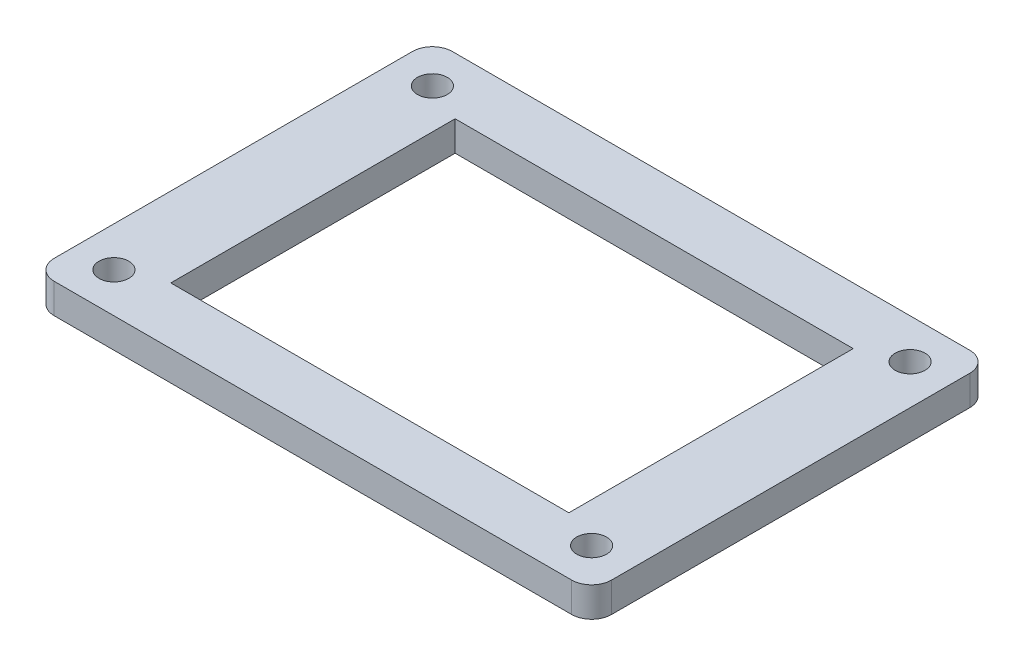
from build123d import *

# Parameters (mm, degrees)
SKETCH2_W           = 56
SKETCH2_H           = 40
SKETCH2_W_2         = 40
SKETCH2_H_2         = 28.571428572
BOSS_EXTRUDE2_DEPTH = 3
SKETCH3_R           = 1.5
CUT_EXTRUDE1_DEPTH  = 4
FILLET1_R           = 2


with BuildPart() as part:
    # Sketch2 → Boss-Extrude2 (new body)
    with BuildSketch(Plane(origin=(0, 0, 0), x_dir=(1, 0, 0), z_dir=(0, 1, 0))):
        Rectangle(SKETCH2_W, SKETCH2_H)
        Rectangle(SKETCH2_W_2, SKETCH2_H_2, mode=Mode.SUBTRACT)
    extrude(amount=BOSS_EXTRUDE2_DEPTH)

    # Sketch3 → Cut-Extrude1 (cut, through all)
    with BuildSketch(Plane(origin=(0, 0, 0), x_dir=(-1, 0, 0), z_dir=(0, -1, 0))):
        with Locations((24, -16)):
            Circle(SKETCH3_R)
        with Locations((-24, 16)):
            Circle(SKETCH3_R)
        with Locations((-24, -16)):
            Circle(SKETCH3_R)
        with Locations((24, 16)):
            Circle(SKETCH3_R)
    extrude(amount=-CUT_EXTRUDE1_DEPTH, mode=Mode.SUBTRACT)

    # Fillet1
    fillet1_edges = [part.edges().sort_by_distance(p)[0] for p in [
        (28, 1.5, 20),
        (-28, 1.5, 20),
        (-28, 1.5, -20),
        (28, 1.5, -20),
    ]]
    fillet(fillet1_edges, radius=FILLET1_R)


solid = part.part
